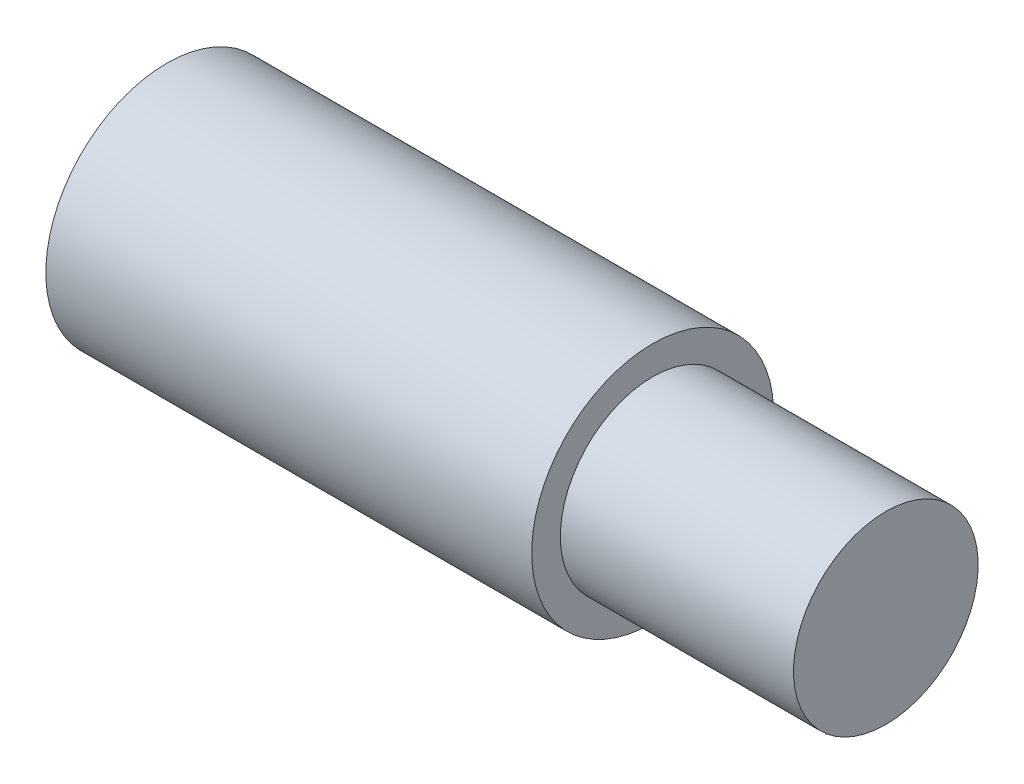
from build123d import *


with BuildPart() as part:
    # Sketch1 → Revolve1 (revolve)
    with BuildSketch(Plane.XY):
        Polygon((0, 3.1623), (12.7, 3.1623), (12.7, 2.413), (18.796, 2.413), (18.796, 0), (0, 0), align=None)
    revolve(axis=Axis((0, 0, 0), (1, 0, 0)))


solid = part.part
